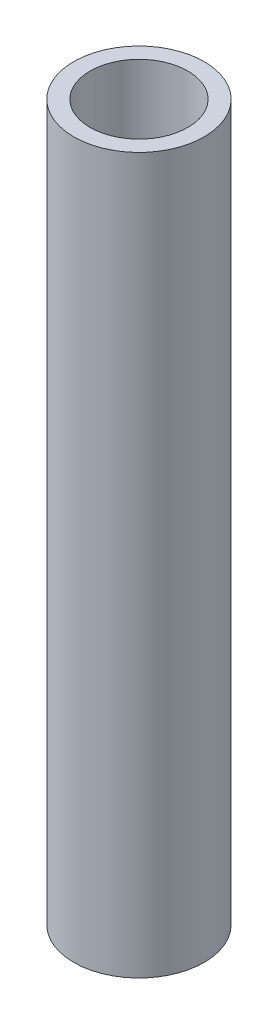
from build123d import *

# Parameters (mm, degrees)
SKETCH1_R           = 6
SKETCH1_R_2         = 4.5
BOSS_EXTRUDE1_DEPTH = 65.8


with BuildPart() as part:
    # Sketch1 → Boss-Extrude1 (new body)
    with BuildSketch(Plane(origin=(0, 0, 0), x_dir=(1, 0, 0), z_dir=(0, 1, 0))):
        Circle(SKETCH1_R)
        Circle(SKETCH1_R_2, mode=Mode.SUBTRACT)
    extrude(amount=BOSS_EXTRUDE1_DEPTH)


solid = part.part
